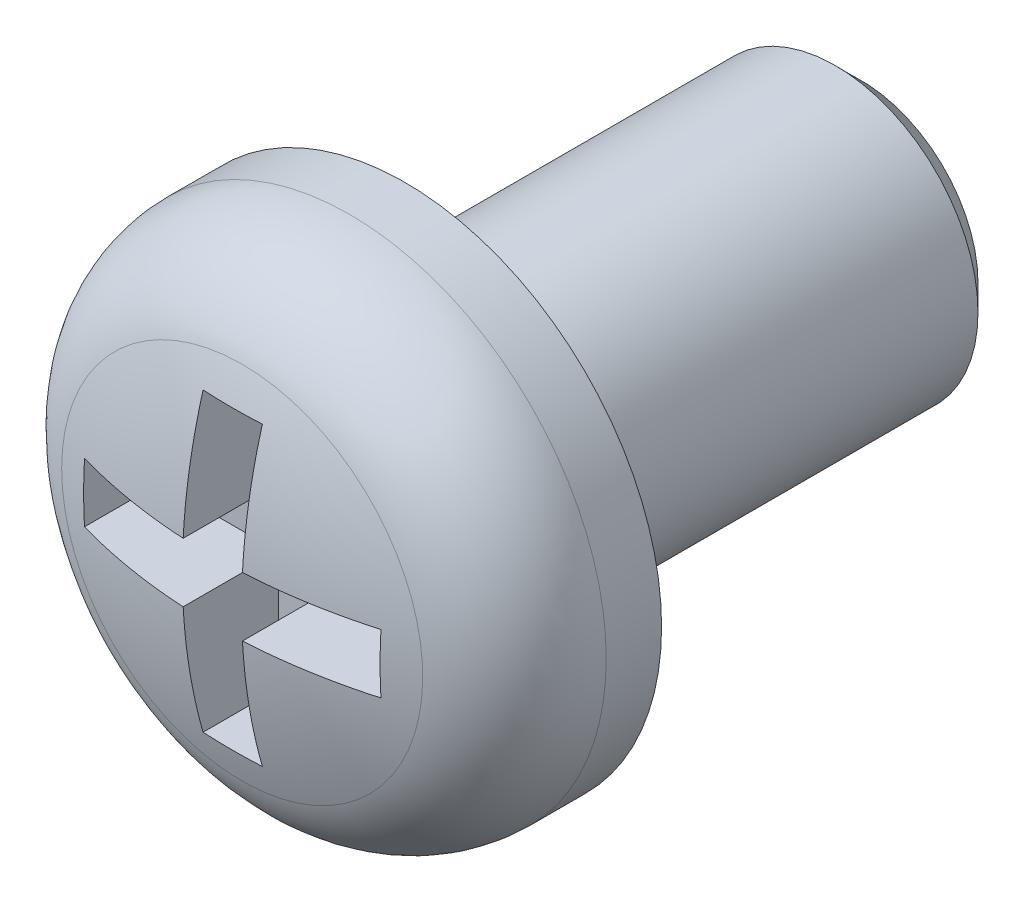
from build123d import *

# Parameters (mm, degrees)
CUT_EXTRUDE2_DEPTH = 0.85
FILLET1_R          = 1
CHAMFER1_SIZE      = 0.225


with BuildPart() as part:
    # Sketch1 → Revolve1 (revolve)
    with BuildSketch(Plane(origin=(0, 0, 0), x_dir=(0, 0, -1), z_dir=(1, 0, 0))):
        with BuildLine():
            Line((-1.133333333, 2.25), (0, 2.25))
            Line((0, 2.25), (0, 1.25))
            Line((0, 1.25), (4, 1.25))
            Line((4, 1.25), (4, 0))
            Line((4, 0), (-1.7, 0))
            ThreePointArc((-1.7, 0), (-1.556155418, 1.1601305), (-1.133333333, 2.25))
        make_face()
    revolve(axis=Axis((0, 0, 33.735969773), (0, 0, -1)))

    # Sketch2 → Cut-Extrude2 (cut)
    with BuildSketch(Plane(origin=(0, 0, 1.7), x_dir=(-1, 0, 0), z_dir=(0, 0, -1))):
        Polygon((0, 1.3), (0.26, 1.3), (0.26, 0.26), (1.3, 0.26), (1.3, 0), (1.3, -0.26), (0.26, -0.26), (0.26, -1.3), (0, -1.3), (-0.26, -1.3), (-0.26, -0.26), (-1.3, -0.26), (-1.3, 0), (-1.3, 0.26), (-0.26, 0.26), (-0.26, 1.3), align=None)
    extrude(amount=CUT_EXTRUDE2_DEPTH, mode=Mode.SUBTRACT)

    # Fillet1
    fillet1_edges = [part.edges().sort_by_distance(p)[0] for p in [
        (0, -2.25, 1.133333333),
    ]]
    fillet(fillet1_edges, radius=FILLET1_R)

    # Chamfer1
    chamfer1_edges = [part.edges().sort_by_distance(p)[0] for p in [
        (0, -1.25, -4),
    ]]
    chamfer(chamfer1_edges, length=CHAMFER1_SIZE)


solid = part.part
